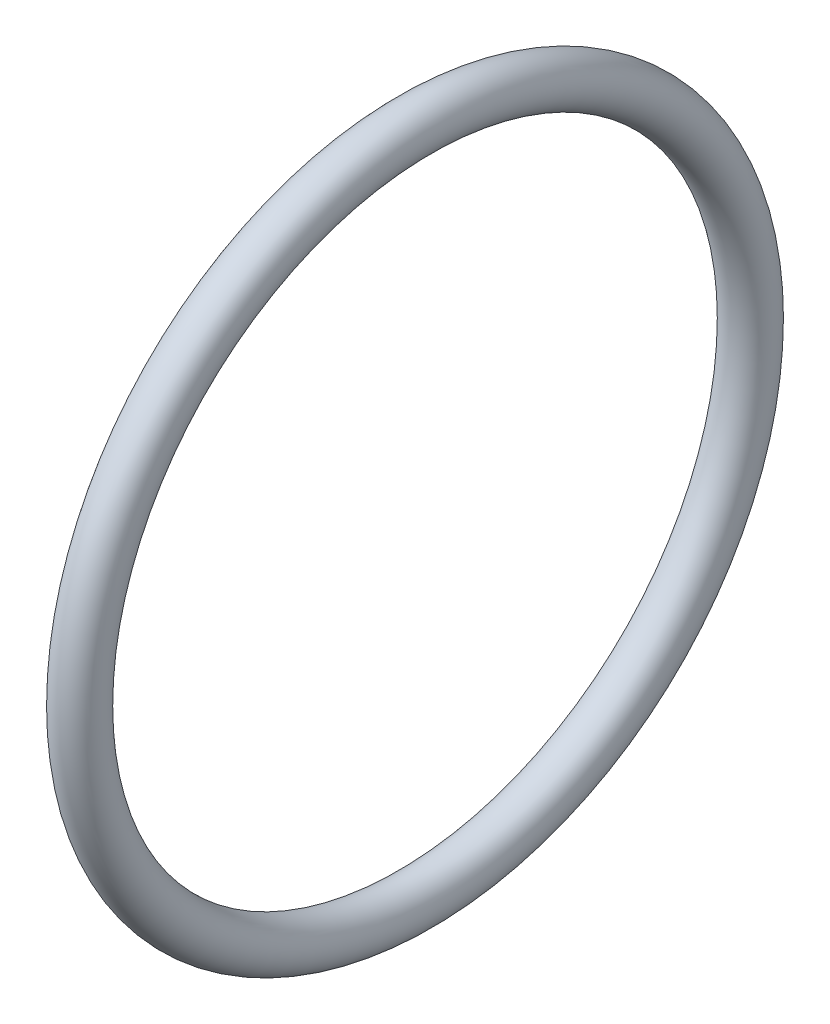
from build123d import *

# Parameters (mm, degrees)
SKETCH3_R = 0.449999989


with BuildPart() as part:
    # Sketch3 → Revolve1 (revolve)
    with BuildSketch(Plane.XY):
        with Locations((10.429399639, 6.449999927)):
            Circle(SKETCH3_R)
    revolve(axis=Axis((0, 0, 0), (1, 0, 0)))


solid = part.part
